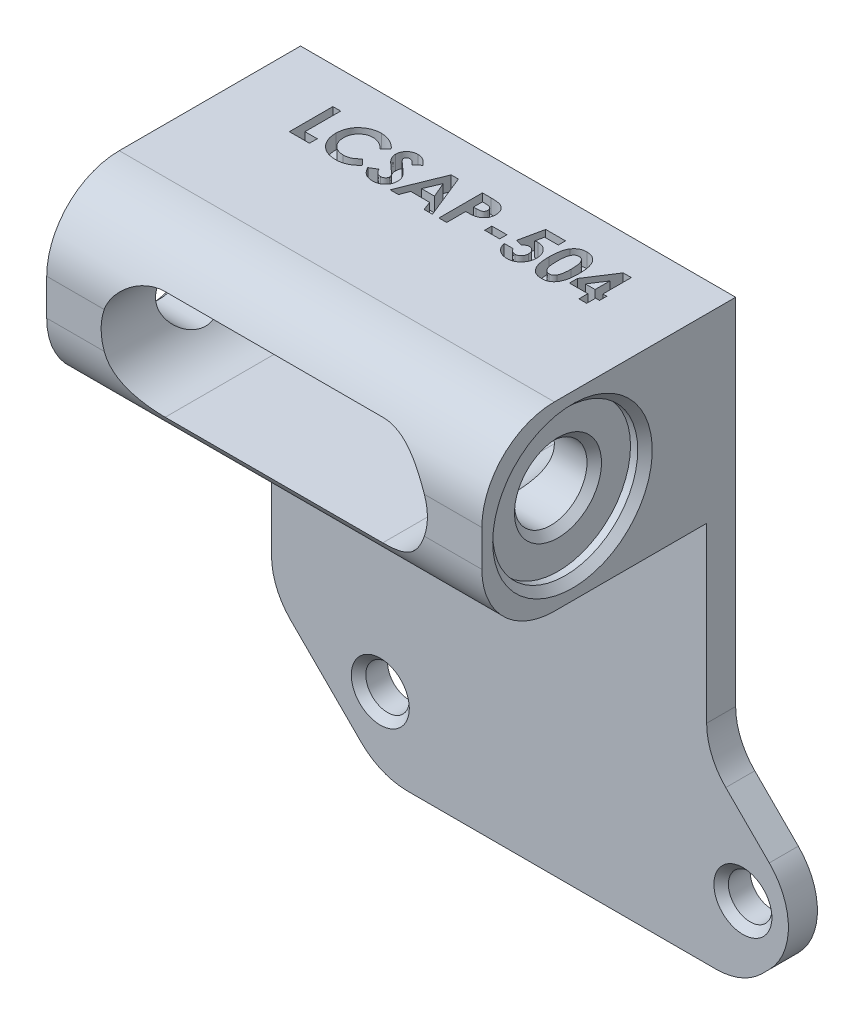
from build123d import *

# Parameters (mm, degrees)
SKETCH1_R           = 1.905
BOSS_EXTRUDE1_DEPTH = 2.54
SKETCH1_3_W         = 50.8
SKETCH1_3_H         = 15.875
BOSS_EXTRUDE2_DEPTH = 22.225
CUT_EXTRUDE6_DEPTH  = 75.180285798
FILLET2_R           = 5.715
SKETCH2_R           = 3.175
CUT_EXTRUDE1_DEPTH  = 67.133840059
SKETCH3_R           = 6.35
CUT_EXTRUDE2_DEPTH  = 1.27
CUT_EXTRUDE3_START  = -1.27
SKETCH4_R           = 6.35
CUT_EXTRUDE3_DEPTH  = 1.27
FILLET1_R           = 6.35
CHAMFER1_SIZE       = 0.635
CUT_EXTRUDE4_DEPTH  = 71.500641843
SKETCH6_W           = 1.318846153
SKETCH6_H           = 0.635
CUT_EXTRUDE5_DEPTH  = 1.27


with BuildPart() as part:
    # Sketch1 → Boss-Extrude1 (new body)
    with BuildSketch(Plane.XY):
        Polygon((50.8, 0), (0, 0), (0, -39.751), (9.525, -49.276), (41.275, -49.276), (50.8, -39.751), align=None)
        with Locations((41.275, -42.926)):
            Circle(SKETCH1_R, mode=Mode.SUBTRACT)
        with Locations((9.525, -42.926)):
            Circle(SKETCH1_R, mode=Mode.SUBTRACT)
    extrude(amount=BOSS_EXTRUDE1_DEPTH)

    # Sketch1_3 → Boss-Extrude2 (add)
    with BuildSketch(Plane.XY):
        with Locations((25.4, -7.9375)):
            Rectangle(SKETCH1_3_W, SKETCH1_3_H)
    extrude(amount=BOSS_EXTRUDE2_DEPTH)

    # Sketch7 → Cut-Extrude6 (cut, through all)
    with BuildSketch(Plane.XY.offset(22.225)):
        Polygon((50.8, 0), (38.1, 0), (38.1, -33.401), (50.8, -46.101), (50.8, -33.401), align=None)
    extrude(amount=-CUT_EXTRUDE6_DEPTH, mode=Mode.SUBTRACT)

    # Fillet2
    fillet2_edges = [part.edges().sort_by_distance(p)[0] for p in [
        (0, -39.751, 1.27),
        (9.525, -49.276, 1.27),
        (41.275, -49.276, 1.27),
        (38.1, -33.401, 1.27),
        (47.625, -42.926, 1.27),
    ]]
    fillet(fillet2_edges, radius=FILLET2_R)

    # Sketch2 → Cut-Extrude1 (cut, through all)
    with BuildSketch(Plane(origin=(38.1, 0, 0), x_dir=(0, 0, -1), z_dir=(1, 0, 0))):
        with Locations((-14.2875, -7.9375)):
            Circle(SKETCH2_R)
    extrude(amount=-CUT_EXTRUDE1_DEPTH, mode=Mode.SUBTRACT)

    # Sketch3 → Cut-Extrude2 (cut)
    with BuildSketch(Plane(origin=(38.1, 0, 0), x_dir=(0, 0, -1), z_dir=(1, 0, 0))):
        with Locations((-14.2875, -7.9375)):
            Circle(SKETCH3_R)
    extrude(amount=-CUT_EXTRUDE2_DEPTH, mode=Mode.SUBTRACT)

    # Sketch4 → Cut-Extrude3 (cut)
    with BuildSketch(Plane.ZY.offset(CUT_EXTRUDE3_START)):
        with Locations((14.2875, -7.9375)):
            Circle(SKETCH4_R)
    extrude(amount=CUT_EXTRUDE3_DEPTH, mode=Mode.SUBTRACT)

    # Fillet1
    fillet1_edges = [part.edges().sort_by_distance(p)[0] for p in [
        (19.05, -15.875, 22.225),
        (19.05, 0, 22.225),
    ]]
    fillet(fillet1_edges, radius=FILLET1_R)

    # Chamfer1
    chamfer1_edges = [part.edges().sort_by_distance(p)[0] for p in [
        (1.27, -7.9375, 17.4625),
        (36.83, -7.9375, 17.4625),
        (0, -7.9375, 7.9375),
        (39.37, -42.926, 2.54),
        (7.62, -42.926, 2.54),
        (38.1, -7.9375, 20.6375),
    ]]
    chamfer(chamfer1_edges, length=CHAMFER1_SIZE)

    # Sketch5 → Cut-Extrude4 (cut, through all)
    with BuildSketch(Plane.XY.offset(22.225)):
        with BuildLine():
            Line((9.525, -3.175), (28.575, -3.175))
            ThreePointArc((28.575, -3.175), (33.3375, -7.9375), (28.575, -12.7))
            Line((28.575, -12.7), (9.525, -12.7))
            ThreePointArc((9.525, -12.7), (4.7625, -7.9375), (9.525, -3.175))
        make_face()
    extrude(amount=-CUT_EXTRUDE4_DEPTH, mode=Mode.SUBTRACT)

    # Sketch6 → Cut-Extrude5 (cut)
    # profile 1 of 9: a face of its own
    with BuildSketch(Plane(origin=(0, 0, 0), x_dir=(1, 0, 0), z_dir=(0, 1, 0))):
        Polygon((31.330228365, -3.077307692), (32.043076923, -3.077307692), (32.043076923, -5.568461538), (32.385, -5.568461538), (32.385, -6.203461538), (32.043076923, -6.203461538), (32.043076923, -6.985), (31.359230769, -6.985), (31.359230769, -6.203461538), (29.747307692, -6.203461538), (29.747307692, -5.511219952), align=None)
        Polygon((31.359230769, -5.568461538), (31.359230769, -4.271748798), (30.515871394, -5.568461538), align=None, mode=Mode.SUBTRACT)
    # profile 2 of 9: a face of its own
    with BuildSketch(Plane(origin=(0, 0, 0), x_dir=(1, 0, 0), z_dir=(0, 1, 0))):
        with BuildLine():
            add(Edge.make_bspline(
                [(28.148359375, -3.077307692), (28.181460367, -3.077799086), (28.246545762, -3.078765297), (28.342404296, -3.089230149), (28.434742569, -3.105039623), (28.523921817, -3.127088325), (28.60930012, -3.156268998), (28.69149888, -3.191197763), (28.769539692, -3.233706706), (28.844417826, -3.28172274), (28.91610444, -3.336083697), (28.982876595, -3.398057995), (29.045953694, -3.466219603), (29.103970349, -3.541599002), (29.158211357, -3.623510536), (29.208498491, -3.711967195), (29.25444679, -3.807401913), (29.296571226, -3.909986911), (29.334239029, -4.021259893), (29.365966573, -4.142497209), (29.393178251, -4.273726545), (29.416146827, -4.415274551), (29.433507358, -4.567329379), (29.445208706, -4.72979001), (29.453238724, -4.902343244), (29.453894079, -5.020713345), (29.454230769, -5.081526442)],
                knots=[0, 0, 0, 0, 0.879237366, 1.728815576, 2.559023295, 3.367336655, 4.166867292, 4.954216142, 5.737608147, 6.525189134, 7.316157332, 8.124696809, 8.942788509, 9.781158001, 10.649253743, 11.551476218, 12.482711956, 13.461909668, 14.496590415, 15.601789533, 16.789733467, 18.056700938, 19.410929216, 20.8549011, 22.384193279, 24, 24, 24, 24], degree=3))
            add(Edge.make_bspline(
                [(29.454230769, -5.081526442), (29.453866898, -5.14310038), (29.453159901, -5.262737435), (29.445542516, -5.436868929), (29.432425019, -5.600509122), (29.415518241, -5.753641084), (29.392360581, -5.896183948), (29.365239741, -6.028506806), (29.333011388, -6.150561692), (29.294102819, -6.262073591), (29.252233364, -6.364838751), (29.206159376, -6.460087394), (29.156683919, -6.548077507), (29.104941811, -6.63013654), (29.04809636, -6.703845435), (28.988914392, -6.77171068), (28.924819021, -6.8311472), (28.858508908, -6.885218086), (28.787554846, -6.931946184), (28.712688567, -6.972813807), (28.632575333, -7.005962303), (28.548675473, -7.034793095), (28.459558897, -7.055490492), (28.366641656, -7.071913197), (28.268874731, -7.080989391), (28.202311071, -7.082115353), (28.168203125, -7.082692308)],
                knots=[0, 0, 0, 0, 1.643780988, 3.193836972, 4.651895693, 6.025988579, 7.305620092, 8.505800249, 9.631074763, 10.672816429, 11.65661981, 12.592235626, 13.49536222, 14.350718032, 15.179365177, 15.97804903, 16.751647189, 17.51006938, 18.259804725, 19.016521909, 19.783502495, 20.571750527, 21.382245291, 22.22305063, 23.089471752, 24, 24, 24, 24], degree=3))
            add(Edge.make_bspline(
                [(28.168203125, -7.082692308), (28.1340961, -7.082104224), (28.067280939, -7.080952176), (27.969249643, -7.071980682), (27.875839986, -7.055423964), (27.786018355, -7.034634195), (27.700409894, -7.006026094), (27.618604112, -6.971885819), (27.541230026, -6.931273189), (27.468073398, -6.88443622), (27.399384007, -6.830727108), (27.334094419, -6.770720333), (27.27234906, -6.704567997), (27.215087228, -6.631529138), (27.161371141, -6.552578674), (27.111760973, -6.466815027), (27.066286538, -6.374363069), (27.023525387, -6.27509393), (26.98637136, -6.166870459), (26.953306, -6.048726236), (26.926219728, -5.919676429), (26.904435135, -5.779762499), (26.887042329, -5.629280858), (26.87410408, -5.468158874), (26.866444384, -5.2963215), (26.865744802, -5.178209113), (26.865384615, -5.117397837)],
                knots=[0, 0, 0, 0, 0.917216111, 1.796812873, 2.643793957, 3.46689424, 4.273913431, 5.068098542, 5.848489301, 6.620921603, 7.401012384, 8.190319798, 9.003608147, 9.831726257, 10.68377682, 11.569763213, 12.493818149, 13.453288342, 14.474581811, 15.568529029, 16.750744269, 18.018426408, 19.375425659, 20.823733699, 22.36466933, 24, 24, 24, 24], degree=3))
            add(Edge.make_bspline(
                [(26.865384615, -5.117397837), (26.866037059, -5.032905355), (26.867295958, -4.869876023), (26.883249648, -4.63434604), (26.906665618, -4.416639369), (26.941058131, -4.217120182), (26.983583997, -4.035049518), (27.038040584, -3.871626761), (27.100035447, -3.724590593), (27.152863035, -3.637485482), (27.178305288, -3.595534856)],
                knots=[0, 0, 0, 0, 1.288568992, 2.486310467, 3.599230591, 4.627010532, 5.572937695, 6.447898582, 7.252493626, 8, 8, 8, 8], degree=3))
            add(Edge.make_bspline(
                [(27.178305288, -3.595534856), (27.207888329, -3.554322574), (27.265729004, -3.473744442), (27.36686504, -3.367960418), (27.475522543, -3.27748874), (27.593933276, -3.204376863), (27.720224525, -3.146720832), (27.855480563, -3.105999026), (27.999201912, -3.082272605), (28.097897761, -3.078987377), (28.148359375, -3.077307692)],
                knots=[0, 0, 0, 0, 1.058512271, 2.069600068, 3.047294572, 4.004278952, 4.967380941, 5.939006123, 6.946246673, 8, 8, 8, 8], degree=3))
        make_face()
        with BuildLine():
            add(Edge.make_bspline(
                [(28.16515024, -3.761153846), (28.135226669, -3.762572164), (28.076560585, -3.76535282), (27.991433301, -3.788956664), (27.911163588, -3.825414074), (27.850104561, -3.869284867), (27.804402486, -3.911340283), (27.772470119, -3.949399067), (27.741676384, -3.991869927), (27.714477806, -4.040669355), (27.688795249, -4.094043929), (27.66369565, -4.152235938), (27.643120569, -4.216674703), (27.622906097, -4.286262825), (27.605196334, -4.36292423), (27.590359435, -4.44728554), (27.57710397, -4.539895365), (27.567858125, -4.640814364), (27.559238222, -4.74993695), (27.553059068, -4.867506208), (27.550475719, -4.993490419), (27.549654551, -5.080253876), (27.549230769, -5.125030048)],
                knots=[0, 0, 0, 0, 1.076674018, 2.110852608, 3.161083442, 4.239746716, 4.804137807, 5.395870207, 6.026861976, 6.692161227, 7.405688833, 8.16177676, 8.973626916, 9.841385931, 10.773283133, 11.807421078, 12.927755683, 14.143907515, 15.458935494, 16.872852025, 18.386167141, 20, 20, 20, 20], degree=3))
            add(Edge.make_bspline(
                [(27.549230769, -5.125030048), (27.549928262, -5.183039744), (27.551265758, -5.294277637), (27.558270931, -5.454241601), (27.572312221, -5.599821688), (27.589776751, -5.73200455), (27.614306395, -5.849932944), (27.64252934, -5.954722584), (27.677382166, -6.045037654), (27.717661323, -6.122184315), (27.762272304, -6.18781282), (27.810699486, -6.243597344), (27.861294097, -6.29190411), (27.91563536, -6.331143101), (27.973593633, -6.361214055), (28.03468507, -6.382843721), (28.098948495, -6.39608414), (28.142955426, -6.39792016), (28.16515024, -6.398846154)],
                knots=[0, 0, 0, 0, 1.771748488, 3.397459088, 4.888034009, 6.237357457, 7.467047327, 8.564189669, 9.548206622, 10.417051504, 11.216568818, 11.965764335, 12.669334354, 13.348544111, 14.005342236, 14.656555988, 15.322436492, 16, 16, 16, 16], degree=3))
            add(Edge.make_bspline(
                [(28.16515024, -6.398846154), (28.186583399, -6.39821252), (28.228546859, -6.396971945), (28.289738981, -6.384237601), (28.3476066, -6.363534325), (28.401974995, -6.334248086), (28.453038634, -6.297006154), (28.50054795, -6.25164487), (28.544144638, -6.197712088), (28.569544266, -6.157685987), (28.582632212, -6.137061298)],
                knots=[0, 0, 0, 0, 0.992283464, 1.942767638, 2.88273346, 3.832339453, 4.79467288, 5.803907806, 6.868395428, 8, 8, 8, 8], degree=3))
            add(Edge.make_bspline(
                [(28.582632212, -6.137061298), (28.598041063, -6.10887832), (28.630352176, -6.0497809), (28.667742651, -5.950056207), (28.699215869, -5.837583236), (28.726304407, -5.712011961), (28.744831315, -5.572847111), (28.760786666, -5.420971144), (28.768482328, -5.255619274), (28.769734069, -5.141062902), (28.770384615, -5.081526442)],
                knots=[0, 0, 0, 0, 0.710965849, 1.490837728, 2.352621235, 3.297892224, 4.334225155, 5.461620853, 6.680770821, 8, 8, 8, 8], degree=3))
            add(Edge.make_bspline(
                [(28.770384615, -5.081526442), (28.770133323, -5.021473177), (28.769649629, -4.905880893), (28.760775239, -4.739934572), (28.748416972, -4.588370148), (28.730340396, -4.451526005), (28.707081596, -4.329069943), (28.678415036, -4.221009969), (28.644619294, -4.127133116), (28.604541572, -4.047532993), (28.560153005, -3.979883808), (28.513033186, -3.921846055), (28.462982874, -3.872294885), (28.410085768, -3.83104383), (28.353117547, -3.79952493), (28.293166377, -3.777269979), (28.230109356, -3.763806479), (28.18709554, -3.762049992), (28.16515024, -3.761153846)],
                knots=[0, 0, 0, 0, 1.793836731, 3.452829483, 4.963243077, 6.335886805, 7.574563692, 8.684454726, 9.672768357, 10.54971625, 11.340229787, 12.085688095, 12.778991901, 13.440269426, 14.083255152, 14.715733572, 15.344777694, 16, 16, 16, 16], degree=3))
        make_face(mode=Mode.SUBTRACT)
    # profile 3 of 9: a face of its own
    with BuildSketch(Plane(origin=(0, 0, 0), x_dir=(1, 0, 0), z_dir=(0, 1, 0))):
        with BuildLine():
            Line((24.642121394, -3.175), (26.376923077, -3.175))
            Line((26.376923077, -3.175), (26.376923077, -3.81))
            Line((26.376923077, -3.81), (25.184008413, -3.81))
            Line((25.184008413, -3.81), (25.035180288, -4.530480769))
            add(Edge.make_bspline(
                [(25.035180288, -4.530480769), (25.055460251, -4.524832544), (25.095456504, -4.513693082), (25.155710908, -4.502521612), (25.214105823, -4.49528062), (25.252424209, -4.494314768), (25.271015625, -4.493846154)],
                knots=[0, 0, 0, 0, 1.05461699, 2.079921384, 3.068411212, 4, 4, 4, 4], degree=3))
            add(Edge.make_bspline(
                [(25.271015625, -4.493846154), (25.311528267, -4.494774478), (25.391387609, -4.496604408), (25.508211693, -4.513976418), (25.620077654, -4.541336807), (25.726643171, -4.580358366), (25.827804143, -4.631145934), (25.923683198, -4.692584654), (26.01439801, -4.764782435), (26.098337103, -4.847784479), (26.175463849, -4.938922602), (26.242521155, -5.037498127), (26.299792279, -5.14210546), (26.345343751, -5.25339484), (26.381296856, -5.370667295), (26.407277372, -5.493997975), (26.42264095, -5.623533047), (26.424712634, -5.711905564), (26.425769231, -5.756977163)],
                knots=[0, 0, 0, 0, 1.01440847, 1.999622559, 2.951875003, 3.895578053, 4.836219714, 5.782137149, 6.743708247, 7.735272588, 8.734977101, 9.730283169, 10.717124674, 11.717316708, 12.737475749, 13.78628267, 14.87096371, 16, 16, 16, 16], degree=3))
            add(Edge.make_bspline(
                [(26.425769231, -5.756977163), (26.424478052, -5.802560429), (26.42193018, -5.892509538), (26.405307649, -6.024766545), (26.375968583, -6.151438899), (26.33566844, -6.272865702), (26.282575581, -6.388154493), (26.218724152, -6.498499579), (26.143034598, -6.603081904), (26.056249691, -6.700829373), (25.961903114, -6.790172435), (25.86144628, -6.868767698), (25.755584929, -6.934904975), (25.644316508, -6.988355077), (25.528279398, -7.030643845), (25.40743838, -7.06142805), (25.281206183, -7.079081081), (25.195510923, -7.081475338), (25.151953125, -7.082692308)],
                knots=[0, 0, 0, 0, 1.06808661, 2.107647099, 3.116961351, 4.110378221, 5.100014249, 6.085620622, 7.093190682, 8.119403071, 9.144090782, 10.133780668, 11.103064255, 12.062861538, 13.020824475, 13.992378307, 14.979551724, 16, 16, 16, 16], degree=3))
            add(Edge.make_bspline(
                [(25.151953125, -7.082692308), (25.113000683, -7.081696751), (25.036178315, -7.079733304), (24.923022339, -7.067664925), (24.813927413, -7.046327917), (24.709472711, -7.015447743), (24.608559196, -6.977441298), (24.512353455, -6.929907056), (24.420326823, -6.873750133), (24.33274062, -6.809995395), (24.251017997, -6.738178154), (24.176430246, -6.659561811), (24.108525804, -6.575137285), (24.048757719, -6.483863035), (23.997313346, -6.385873913), (23.951691427, -6.282324743), (23.914349429, -6.172134142), (23.89539944, -6.095743896), (23.885769231, -6.056923077)],
                knots=[0, 0, 0, 0, 1.054957082, 2.080596141, 3.077793124, 4.061112343, 5.027190972, 5.994718051, 6.962465889, 7.943658696, 8.924948258, 9.904494768, 10.875059, 11.855380583, 12.854004648, 13.869083016, 14.917087635, 16, 16, 16, 16], degree=3))
            Line((23.885769231, -6.056923077), (24.667307692, -6.056923077))
            add(Edge.make_bspline(
                [(24.667307692, -6.056923077), (24.681594234, -6.083824324), (24.709358498, -6.136103827), (24.762172266, -6.205512722), (24.821293926, -6.264701647), (24.886190169, -6.314248888), (24.957281483, -6.351368838), (25.031671029, -6.379518891), (25.110293333, -6.395785764), (25.163838594, -6.397819285), (25.190877404, -6.398846154)],
                knots=[0, 0, 0, 0, 1.104910296, 2.147267069, 3.153527244, 4.136738762, 5.099945312, 6.05603338, 7.018353, 8, 8, 8, 8], degree=3))
            add(Edge.make_bspline(
                [(25.190877404, -6.398846154), (25.209723092, -6.398137092), (25.2468023, -6.396742), (25.301432651, -6.389361616), (25.35357972, -6.375383335), (25.40363121, -6.356026666), (25.451721571, -6.331886714), (25.497161411, -6.301411596), (25.540741302, -6.266333606), (25.58179778, -6.226081494), (25.618983116, -6.181209752), (25.651590588, -6.132992006), (25.680746164, -6.082499665), (25.702342145, -6.027732601), (25.720027428, -5.970326177), (25.733051585, -5.909847359), (25.740834988, -5.846225514), (25.741555523, -5.802792663), (25.741923077, -5.780637019)],
                knots=[0, 0, 0, 0, 0.978869489, 1.925942215, 2.855067702, 3.774946051, 4.70828698, 5.642468714, 6.60995405, 7.609372294, 8.622401667, 9.629904756, 10.629323, 11.642352373, 12.678539694, 13.745912462, 14.850161547, 16, 16, 16, 16], degree=3))
            add(Edge.make_bspline(
                [(25.741923077, -5.780637019), (25.741496488, -5.758995658), (25.740666123, -5.716870222), (25.733797173, -5.655014994), (25.721508754, -5.596325577), (25.704765678, -5.540352453), (25.683332542, -5.487435519), (25.657139817, -5.437259788), (25.626075605, -5.39007888), (25.589973129, -5.34685335), (25.55147382, -5.307205666), (25.510113191, -5.272530117), (25.46626388, -5.243751819), (25.421288449, -5.218627528), (25.373391643, -5.200342616), (25.323650466, -5.187750472), (25.272117229, -5.178510863), (25.236967527, -5.177968002), (25.219116587, -5.177692308)],
                knots=[0, 0, 0, 0, 1.166249705, 2.270133367, 3.348514167, 4.393962215, 5.415026464, 6.420877785, 7.440098956, 8.453121383, 9.451844239, 10.415694839, 11.355045125, 12.27538808, 13.187007209, 14.108269027, 15.039275622, 16, 16, 16, 16], degree=3))
            add(Edge.make_bspline(
                [(25.219116587, -5.177692308), (25.199726317, -5.178428061), (25.160864057, -5.179902668), (25.103124464, -5.19190115), (25.046081051, -5.211319195), (24.989416597, -5.238109466), (24.933693595, -5.273169478), (24.877441487, -5.314290851), (24.822543152, -5.364461445), (24.787637264, -5.401828618), (24.769579327, -5.421159856)],
                knots=[0, 0, 0, 0, 0.88288272, 1.769486374, 2.674910571, 3.623812639, 4.617874466, 5.670434592, 6.794841017, 8, 8, 8, 8], degree=3))
            Line((24.769579327, -5.421159856), (24.194110577, -5.289122596))
            Line((24.194110577, -5.289122596), (24.642121394, -3.175))
        make_face()
    # profile 4 of 9: a face of its own
    with BuildSketch(Plane(origin=(0, 0, 0), x_dir=(1, 0, 0), z_dir=(0, 1, 0))):
        with Locations((22.689038462, -5.592884615)):
            Rectangle(SKETCH6_W, SKETCH6_H)
    # profile 5 of 9: a face of its own
    with BuildSketch(Plane(origin=(0, 0, 0), x_dir=(1, 0, 0), z_dir=(0, 1, 0))):
        with BuildLine():
            Line((19.098846154, -3.175), (19.862067308, -3.175))
            add(Edge.make_bspline(
                [(19.862067308, -3.175), (19.911935188, -3.175223219), (20.008140781, -3.175653856), (20.146877163, -3.180875899), (20.274868267, -3.190234118), (20.392084689, -3.201799397), (20.498478233, -3.218013468), (20.594182134, -3.236601631), (20.679216253, -3.259247423), (20.754539478, -3.286127665), (20.822139638, -3.31781842), (20.886111194, -3.351571335), (20.945008379, -3.39185425), (21.001803913, -3.434325642), (21.053250698, -3.483042787), (21.102558292, -3.534763489), (21.147638383, -3.591538947), (21.188699857, -3.65268191), (21.22594894, -3.717062719), (21.258492232, -3.784796465), (21.284889527, -3.855990332), (21.307033575, -3.930183776), (21.324819891, -4.007373562), (21.336659029, -4.088034416), (21.344700767, -4.171603132), (21.345410339, -4.228480053), (21.345769231, -4.257247596)],
                knots=[0, 0, 0, 0, 1.698747864, 3.27724071, 4.728299578, 6.070144658, 7.288476769, 8.393259625, 9.389771311, 10.283485332, 11.113357557, 11.931608583, 12.74405601, 13.541433047, 14.344816069, 15.154114104, 15.974336324, 16.810834471, 17.661136416, 18.50621059, 19.367396281, 20.244825668, 21.142564693, 22.063065223, 23.020325768, 24, 24, 24, 24], degree=3))
            add(Edge.make_bspline(
                [(21.345769231, -4.257247596), (21.345249959, -4.289072444), (21.344229528, -4.35161218), (21.334226006, -4.443287761), (21.317136832, -4.530692127), (21.294802174, -4.614562375), (21.263658083, -4.693518653), (21.228077421, -4.769444883), (21.184301921, -4.840212326), (21.134281415, -4.906706198), (21.079653314, -4.969467124), (21.019120752, -5.026683003), (20.953837505, -5.078743873), (20.884181474, -5.126195335), (20.809891149, -5.16894167), (20.731020135, -5.207383151), (20.647029855, -5.240290301), (20.588541551, -5.257500474), (20.558888221, -5.266225962)],
                knots=[0, 0, 0, 0, 1.102006807, 2.165578795, 3.188629044, 4.184801286, 5.166646146, 6.124351954, 7.085497154, 8.042432466, 9.003981491, 9.963833307, 10.922997304, 11.89326795, 12.880200226, 13.889073926, 14.929769137, 16, 16, 16, 16], degree=3))
            add(Edge.make_bspline(
                [(20.558888221, -5.266225962), (20.539356832, -5.271085403), (20.497045554, -5.281612517), (20.42703201, -5.292300181), (20.346348752, -5.30212683), (20.254734877, -5.310571646), (20.152137569, -5.316312152), (20.038656168, -5.320795233), (19.914239247, -5.324054895), (19.82772464, -5.324170563), (19.782692308, -5.324230769)],
                knots=[0, 0, 0, 0, 0.618981996, 1.340914327, 2.176866532, 3.120127938, 4.170906482, 5.338178032, 6.614476169, 8, 8, 8, 8], degree=3))
            Line((19.782692308, -5.324230769), (19.782692308, -6.985))
            Line((19.782692308, -6.985), (19.098846154, -6.985))
            Line((19.098846154, -6.985), (19.098846154, -3.175))
        make_face()
        with BuildLine():
            Line((19.782692308, -4.640384615), (20.024633413, -4.640384615))
            add(Edge.make_bspline(
                [(20.024633413, -4.640384615), (20.068658417, -4.640105463), (20.149665079, -4.639591818), (20.260291572, -4.632164211), (20.34919315, -4.620820755), (20.419427047, -4.604551616), (20.474883361, -4.579861043), (20.52271096, -4.5512987), (20.563733913, -4.5151824), (20.599253752, -4.473913349), (20.627650793, -4.426493141), (20.647342662, -4.373693921), (20.660134113, -4.316625059), (20.661315522, -4.276908908), (20.661923077, -4.256484375)],
                knots=[0, 0, 0, 0, 1.8619151, 3.425951444, 4.686033666, 5.651700536, 6.461346321, 7.243864085, 7.999046032, 8.762387399, 9.539336099, 10.322741239, 11.137448474, 12, 12, 12, 12], degree=3))
            add(Edge.make_bspline(
                [(20.661923077, -4.256484375), (20.661321772, -4.238639727), (20.660155095, -4.204016818), (20.651584372, -4.154047374), (20.637925104, -4.107465544), (20.61813335, -4.064757813), (20.592547298, -4.025996749), (20.561352724, -3.991197621), (20.524949914, -3.959615176), (20.496844817, -3.942898106), (20.482566106, -3.934405048)],
                knots=[0, 0, 0, 0, 1.102301479, 2.1387299, 3.123554645, 4.094223062, 5.036071848, 5.982632524, 6.975082478, 8, 8, 8, 8], degree=3))
            add(Edge.make_bspline(
                [(20.482566106, -3.934405048), (20.470471213, -3.928288314), (20.444863848, -3.915337935), (20.401252022, -3.900282173), (20.35092464, -3.887580978), (20.293541937, -3.87703911), (20.229332828, -3.868857525), (20.158308769, -3.862600659), (20.080365241, -3.86008453), (20.026160182, -3.859270331), (19.997920673, -3.858846154)],
                knots=[0, 0, 0, 0, 0.656809284, 1.390599849, 2.23162475, 3.173112763, 4.218524733, 5.370385145, 6.63003504, 8, 8, 8, 8], degree=3))
            Line((19.997920673, -3.858846154), (19.782692308, -3.858846154))
            Line((19.782692308, -3.858846154), (19.782692308, -4.640384615))
        make_face(mode=Mode.SUBTRACT)
    # profile 6 of 9: a face of its own
    with BuildSketch(Plane(origin=(0, 0, 0), x_dir=(1, 0, 0), z_dir=(0, 1, 0))):
        Polygon((16.36422476, -3.175), (16.998461538, -3.175), (18.537115385, -6.985), (17.80671274, -6.985), (17.510582933, -6.203461538), (15.850576923, -6.203461538), (15.554447115, -6.985), (14.824807692, -6.985), align=None)
        Polygon((16.680961538, -4.196953125), (16.110072115, -5.519615385), (17.251850962, -5.519615385), align=None, mode=Mode.SUBTRACT)
    # profile 7 of 9: a face of its own
    with BuildSketch(Plane(origin=(0, 0, 0), x_dir=(1, 0, 0), z_dir=(0, 1, 0))):
        with BuildLine():
            Line((14.409615385, -3.68406851), (13.898257212, -4.151923077))
            add(Edge.make_bspline(
                [(13.898257212, -4.151923077), (13.87635282, -4.121024656), (13.834299443, -4.061703995), (13.766135305, -3.982272233), (13.698278964, -3.914511029), (13.63010177, -3.858703458), (13.560999428, -3.815188591), (13.491091889, -3.784379585), (13.420775479, -3.764794008), (13.373533706, -3.762355132), (13.350264423, -3.761153846)],
                knots=[0, 0, 0, 0, 1.299362458, 2.494594718, 3.587462134, 4.587049575, 5.512617175, 6.380583204, 7.202344345, 8, 8, 8, 8], degree=3))
            add(Edge.make_bspline(
                [(13.350264423, -3.761153846), (13.328559503, -3.761915036), (13.286653006, -3.763384694), (13.226912185, -3.777992984), (13.173873434, -3.803204747), (13.127588515, -3.836171248), (13.09092403, -3.87588824), (13.061650283, -3.917541151), (13.045166703, -3.963516546), (13.04299714, -3.995094301), (13.041923077, -4.010727163)],
                knots=[0, 0, 0, 0, 1.185010067, 2.2879431, 3.333075148, 4.379039566, 5.372662701, 6.27520591, 7.14612461, 8, 8, 8, 8], degree=3))
            add(Edge.make_bspline(
                [(13.041923077, -4.010727163), (13.042596138, -4.026585458), (13.043951588, -4.058521861), (13.057043394, -4.105328636), (13.076776485, -4.151064304), (13.095632259, -4.178905781), (13.105270433, -4.193137019)],
                knots=[0, 0, 0, 0, 0.967525499, 1.948461899, 2.951351359, 4, 4, 4, 4], degree=3))
            add(Edge.make_bspline(
                [(13.105270433, -4.193137019), (13.114032576, -4.204198812), (13.134201871, -4.229661597), (13.172660587, -4.26999068), (13.220956658, -4.319397337), (13.280948617, -4.376182618), (13.350146033, -4.442388743), (13.431756297, -4.515413124), (13.523430309, -4.597517242), (13.588590072, -4.654691576), (13.622734375, -4.684651442)],
                knots=[0, 0, 0, 0, 0.473873513, 1.090794244, 1.870441696, 2.795289791, 3.865433203, 5.087734844, 6.473946851, 8, 8, 8, 8], degree=3))
            add(Edge.make_bspline(
                [(13.622734375, -4.684651442), (13.654783715, -4.712388529), (13.715606702, -4.765027757), (13.802145736, -4.83974069), (13.878199133, -4.906958093), (13.944874819, -4.965671179), (14.001162055, -5.016495981), (14.047297473, -5.059675441), (14.083844539, -5.094368935), (14.104619406, -5.115323826), (14.113485577, -5.124266827)],
                knots=[0, 0, 0, 0, 1.543621617, 2.929473131, 4.163658386, 5.240097082, 6.164993805, 6.925417477, 7.541396219, 8, 8, 8, 8], degree=3))
            add(Edge.make_bspline(
                [(14.113485577, -5.124266827), (14.147121982, -5.160668621), (14.211782964, -5.230645652), (14.295819447, -5.339088044), (14.364984191, -5.44494993), (14.418491348, -5.550223274), (14.458902106, -5.65642696), (14.487392225, -5.766165628), (14.504455147, -5.880585978), (14.50634953, -5.958663899), (14.507307692, -5.998155048)],
                knots=[0, 0, 0, 0, 1.206664779, 2.319633467, 3.337109185, 4.282041471, 5.190008762, 6.099243693, 7.03861361, 8, 8, 8, 8], degree=3))
            add(Edge.make_bspline(
                [(14.507307692, -5.998155048), (14.506625697, -6.03663433), (14.505287596, -6.112132112), (14.488898426, -6.222611871), (14.465528432, -6.328345796), (14.429394322, -6.428183351), (14.385354282, -6.52376334), (14.330143731, -6.61359693), (14.26530651, -6.698593274), (14.190993099, -6.777232958), (14.108793642, -6.848593021), (14.020626913, -6.912119435), (13.925630772, -6.964568581), (13.824616852, -7.007756712), (13.717639223, -7.041020788), (13.604825328, -7.06560604), (13.48600261, -7.080361721), (13.404749923, -7.081904252), (13.363239183, -7.082692308)],
                knots=[0, 0, 0, 0, 1.043214005, 2.046824704, 3.02475056, 3.976699089, 4.921714032, 5.875962561, 6.831408892, 7.817874052, 8.806269674, 9.781291748, 10.760897367, 11.74438705, 12.757449933, 13.795994037, 14.874007457, 16, 16, 16, 16], degree=3))
            add(Edge.make_bspline(
                [(13.363239183, -7.082692308), (13.330653605, -7.082114218), (13.266115473, -7.080969268), (13.170996024, -7.071621709), (13.079147443, -7.056535743), (12.99067319, -7.034913047), (12.905174672, -7.007514158), (12.822648378, -6.974047466), (12.743664015, -6.933994248), (12.667623949, -6.888178158), (12.594897829, -6.834979642), (12.524566062, -6.775486327), (12.457327249, -6.708783179), (12.392858457, -6.635027948), (12.331572174, -6.554011777), (12.271462281, -6.466862966), (12.215200242, -6.371964152), (12.180444678, -6.305391867), (12.162692308, -6.271388221)],
                knots=[0, 0, 0, 0, 1.016823716, 2.013894106, 2.979844003, 3.91962641, 4.853723003, 5.779685073, 6.695824784, 7.614987388, 8.547259901, 9.504950863, 10.487499108, 11.500346958, 12.559593716, 13.656357062, 14.802919212, 16, 16, 16, 16], degree=3))
            Line((12.162692308, -6.271388221), (12.764110577, -5.910384615))
            add(Edge.make_bspline(
                [(12.764110577, -5.910384615), (12.786316139, -5.948983196), (12.8288861, -6.022979974), (12.901024879, -6.122404024), (12.974927375, -6.207544265), (13.052302148, -6.276895838), (13.132208349, -6.331386063), (13.215031944, -6.370328557), (13.300831124, -6.394433918), (13.359273627, -6.397377739), (13.388425481, -6.398846154)],
                knots=[0, 0, 0, 0, 1.283663364, 2.460892379, 3.537111102, 4.529833553, 5.449777664, 6.316464042, 7.160231139, 8, 8, 8, 8], degree=3))
            add(Edge.make_bspline(
                [(13.388425481, -6.398846154), (13.41807709, -6.397646967), (13.47560553, -6.395320369), (13.557720016, -6.373830284), (13.633005687, -6.340089276), (13.698082065, -6.291945509), (13.753184638, -6.236380285), (13.7938535, -6.174561433), (13.819401954, -6.107674927), (13.822103044, -6.06121116), (13.823461538, -6.037842548)],
                knots=[0, 0, 0, 0, 1.13588714, 2.203786484, 3.234766741, 4.283437687, 5.291419208, 6.222934724, 7.106237994, 8, 8, 8, 8], degree=3))
            add(Edge.make_bspline(
                [(13.823461538, -6.037842548), (13.822207025, -6.016101857), (13.819658601, -5.971937725), (13.800887693, -5.906272762), (13.771543039, -5.840637662), (13.736826244, -5.786801977), (13.701497559, -5.741726818), (13.667715367, -5.702671231), (13.626577593, -5.659521645), (13.578188545, -5.612223781), (13.523187569, -5.560361264), (13.461528333, -5.503939172), (13.392504774, -5.443454517), (13.343718786, -5.402252967), (13.318209135, -5.380709135)],
                knots=[0, 0, 0, 0, 0.916159276, 1.861089862, 2.860218735, 3.940849679, 4.552606315, 5.27541173, 6.11797699, 7.06649574, 8.129236253, 9.306560635, 10.591630461, 12, 12, 12, 12], degree=3))
            add(Edge.make_bspline(
                [(13.318209135, -5.380709135), (13.269714272, -5.339677831), (13.176637952, -5.260926339), (13.045109304, -5.144612865), (12.926590215, -5.035907265), (12.822104343, -4.933465702), (12.730320377, -4.839180033), (12.651859918, -4.752284434), (12.587584889, -4.672108624), (12.51994928, -4.577145743), (12.455681929, -4.461426947), (12.400136701, -4.322203821), (12.364101301, -4.18299836), (12.360064036, -4.08954348), (12.358076923, -4.043545673)],
                knots=[0, 0, 0, 0, 1.345494975, 2.582412109, 3.71882943, 4.751509156, 5.681369928, 6.505683931, 7.230279997, 7.856715994, 8.973648664, 10.023341002, 11.027102913, 12, 12, 12, 12], degree=3))
            add(Edge.make_bspline(
                [(12.358076923, -4.043545673), (12.358903361, -4.010926497), (12.360531531, -3.946663216), (12.375055063, -3.852173425), (12.396761035, -3.760998716), (12.428284338, -3.673471736), (12.469197779, -3.589702116), (12.518885563, -3.509279769), (12.578119249, -3.432944883), (12.644871614, -3.360748063), (12.718415629, -3.294768385), (12.797006756, -3.236534709), (12.880200161, -3.187349699), (12.96748691, -3.146547162), (13.059407881, -3.115315411), (13.155285898, -3.09317679), (13.25525848, -3.080009444), (13.323257672, -3.078219496), (13.357896635, -3.077307692)],
                knots=[0, 0, 0, 0, 1.010766082, 1.991317756, 2.957454644, 3.913069143, 4.869106762, 5.843196583, 6.838735724, 7.860187025, 8.887984031, 9.89767229, 10.887916223, 11.879572884, 12.879850636, 13.892031539, 14.926195476, 16, 16, 16, 16], degree=3))
            add(Edge.make_bspline(
                [(13.357896635, -3.077307692), (13.402787015, -3.078949878), (13.492213428, -3.082221287), (13.624432958, -3.107802634), (13.753579467, -3.148031997), (13.857648145, -3.196564297), (13.940453649, -3.243577559), (14.003916333, -3.286861449), (14.068493029, -3.336445471), (14.13470451, -3.392485877), (14.201320463, -3.456038544), (14.270235098, -3.525590548), (14.340509369, -3.601742983), (14.386176503, -3.656145929), (14.409615385, -3.68406851)],
                knots=[0, 0, 0, 0, 1.282922637, 2.555718331, 3.837320111, 5.142675274, 5.830281639, 6.55870424, 7.337177975, 8.157850921, 9.037902056, 9.96903443, 10.957596896, 12, 12, 12, 12], degree=3))
        make_face()
    # profile 8 of 9: a face of its own
    with BuildSketch(Plane(origin=(0, 0, 0), x_dir=(1, 0, 0), z_dir=(0, 1, 0))):
        with BuildLine():
            Line((11.771923077, -3.835949519), (11.270486779, -4.315252404))
            add(Edge.make_bspline(
                [(11.270486779, -4.315252404), (11.227950867, -4.2712702), (11.144864905, -4.185359176), (11.010982153, -4.071620551), (10.871748965, -3.976834797), (10.729873846, -3.897006838), (10.582804873, -3.836611298), (10.432242564, -3.79260005), (10.277225534, -3.765768056), (10.172315971, -3.762698001), (10.119549279, -3.761153846)],
                knots=[0, 0, 0, 0, 1.115251505, 2.178435587, 3.19620269, 4.182487026, 5.141301733, 6.088180966, 7.038406374, 8, 8, 8, 8], degree=3))
            add(Edge.make_bspline(
                [(10.119549279, -3.761153846), (10.075482678, -3.762373783), (9.988522097, -3.764781193), (9.860841176, -3.782429886), (9.738707776, -3.812442257), (9.621703815, -3.853804863), (9.510173583, -3.90732588), (9.403883243, -3.972963884), (9.303094849, -4.05012607), (9.209139757, -4.138413199), (9.12319294, -4.234873521), (9.047253456, -4.337796454), (8.983641956, -4.446946209), (8.931437033, -4.561217395), (8.890771416, -4.681138918), (8.861731056, -4.80663004), (8.844934888, -4.937840213), (8.842427947, -5.027035911), (8.841153846, -5.072367788)],
                knots=[0, 0, 0, 0, 1.035432265, 2.043311493, 3.022114605, 3.98653278, 4.95457646, 5.923598177, 6.917315552, 7.932509744, 8.948865224, 9.949768934, 10.933144597, 11.912367597, 12.897413939, 13.903909035, 14.934704909, 16, 16, 16, 16], degree=3))
            add(Edge.make_bspline(
                [(8.841153846, -5.072367788), (8.841521028, -5.104184872), (8.84224475, -5.166896997), (8.850167167, -5.259665635), (8.862924127, -5.349673146), (8.881386609, -5.436783192), (8.904474125, -5.521071263), (8.931561037, -5.603264508), (8.96554117, -5.682227202), (9.003259631, -5.758876445), (9.047125766, -5.831120766), (9.094421551, -5.900011723), (9.145706109, -5.965211617), (9.201311612, -6.026453911), (9.262020639, -6.082781523), (9.326264085, -6.135888294), (9.395125649, -6.184444779), (9.467174901, -6.229669558), (9.543034256, -6.268956708), (9.620645475, -6.304543276), (9.701185299, -6.33344486), (9.783673107, -6.356742174), (9.867814118, -6.37655306), (9.954431308, -6.388751231), (10.042773815, -6.397988763), (10.102478521, -6.398559127), (10.132524038, -6.398846154)],
                knots=[0, 0, 0, 0, 1.103660481, 2.175337485, 3.227646561, 4.255952547, 5.262355991, 6.258840057, 7.255597736, 8.242457506, 9.22035537, 10.185017736, 11.140346927, 12.096287581, 13.051739095, 14.01125915, 14.986044842, 15.97314143, 16.960198552, 17.947847494, 18.933482797, 19.925264591, 20.920966487, 21.929612487, 22.958107872, 24, 24, 24, 24], degree=3))
            add(Edge.make_bspline(
                [(10.132524038, -6.398846154), (10.183486399, -6.397372052), (10.283614186, -6.394475825), (10.43056611, -6.37182774), (10.570596653, -6.334572923), (10.682480387, -6.290577148), (10.770138338, -6.24713075), (10.83687104, -6.20694497), (10.905877855, -6.161992764), (10.976012638, -6.110577586), (11.048064268, -6.053316439), (11.120760866, -5.988955196), (11.195963479, -5.919613182), (11.245227965, -5.870122424), (11.270486779, -5.844747596)],
                knots=[0, 0, 0, 0, 1.404581149, 2.759636711, 4.088442092, 5.392261763, 6.066678138, 6.783632037, 7.538459478, 8.336747902, 9.180226004, 10.074962426, 11.012997595, 12, 12, 12, 12], degree=3))
            Line((11.270486779, -5.844747596), (11.756658654, -6.355342548))
            add(Edge.make_bspline(
                [(11.756658654, -6.355342548), (11.722483388, -6.388337694), (11.655780577, -6.452737164), (11.555161239, -6.544178401), (11.454668535, -6.626348518), (11.356730158, -6.702229929), (11.259741776, -6.769612026), (11.163713675, -6.828562102), (11.069732935, -6.880571091), (10.975848015, -6.924761887), (10.881474714, -6.962284463), (10.784375679, -6.994588938), (10.684254067, -7.021917361), (10.580498382, -7.043967809), (10.474076393, -7.061649292), (10.363992133, -7.073584191), (10.250943589, -7.081607626), (10.17426101, -7.082328599), (10.135576923, -7.082692308)],
                knots=[0, 0, 0, 0, 1.244526981, 2.429050516, 3.560637417, 4.644440555, 5.67424972, 6.652764056, 7.595344123, 8.486817594, 9.369275933, 10.254498637, 11.166417451, 12.086725134, 13.032340136, 13.991389299, 14.986715468, 16, 16, 16, 16], degree=3))
            add(Edge.make_bspline(
                [(10.135576923, -7.082692308), (10.064519047, -7.080880901), (9.925478536, -7.077336481), (9.721718292, -7.051074729), (9.528151529, -7.007047365), (9.344307337, -6.944780528), (9.170244173, -6.865237562), (9.006006568, -6.767721621), (8.851859237, -6.652491789), (8.709047386, -6.520898672), (8.57986727, -6.375565121), (8.465687007, -6.219516758), (8.37123709, -6.051986663), (8.292813288, -5.87544979), (8.231486906, -5.689100533), (8.18832353, -5.492737319), (8.161704991, -5.286549749), (8.158792885, -5.145718885), (8.157307692, -5.073894231)],
                knots=[0, 0, 0, 0, 1.078019885, 2.10938526, 3.111377082, 4.085535484, 5.04941344, 6.010039228, 6.978205633, 7.964457913, 8.951525778, 9.924444315, 10.892603023, 11.863865945, 12.85144698, 13.863884204, 14.910567087, 16, 16, 16, 16], degree=3))
            add(Edge.make_bspline(
                [(8.157307692, -5.073894231), (8.157935263, -5.027050804), (8.159178954, -4.934218582), (8.172250267, -4.797469197), (8.190472436, -4.664163007), (8.219380252, -4.535684173), (8.254225772, -4.410301847), (8.297560754, -4.289378789), (8.349315987, -4.172567454), (8.407823277, -4.059672293), (8.474011989, -3.95143289), (8.547952047, -3.848779192), (8.627739944, -3.750918731), (8.715292855, -3.659149808), (8.80933852, -3.572666674), (8.910301546, -3.491937998), (9.017574689, -3.415806039), (9.1314483, -3.346234057), (9.249710115, -3.2833025), (9.370868544, -3.22779418), (9.494625914, -3.181402007), (9.620458966, -3.14292141), (9.748899346, -3.114198366), (9.879030277, -3.092455948), (10.011959017, -3.080301798), (10.101209151, -3.078312086), (10.146262019, -3.077307692)],
                knots=[0, 0, 0, 0, 1.071919942, 2.124283339, 3.142214191, 4.149696895, 5.136002878, 6.119640489, 7.086990633, 8.058538607, 9.028339693, 9.988281803, 10.952401235, 11.916291999, 12.888973767, 13.874849856, 14.873389453, 15.898127285, 16.927174885, 17.938320013, 18.946391617, 19.950418109, 20.947802303, 21.956882652, 22.968648068, 24, 24, 24, 24], degree=3))
            add(Edge.make_bspline(
                [(10.146262019, -3.077307692), (10.184696736, -3.077883436), (10.261166554, -3.079028936), (10.375042946, -3.088577929), (10.488008609, -3.103574525), (10.599659089, -3.126201195), (10.710793026, -3.153061912), (10.819949995, -3.188232316), (10.928852006, -3.227436359), (11.035791093, -3.274296787), (11.140916528, -3.325449177), (11.241765581, -3.383483421), (11.340031499, -3.444828157), (11.433536767, -3.513114035), (11.524032942, -3.585864198), (11.61104681, -3.663418068), (11.693814774, -3.747068695), (11.745755353, -3.806172802), (11.771923077, -3.835949519)],
                knots=[0, 0, 0, 0, 0.996412454, 1.982464992, 2.961075852, 3.949442424, 4.934965278, 5.923860011, 6.921385422, 7.934793307, 8.949617135, 9.951082467, 10.950285876, 11.951772932, 12.951063433, 13.960125323, 14.972308753, 16, 16, 16, 16], degree=3))
        make_face()
    # profile 9 of 9: a face of its own
    with BuildSketch(Plane(origin=(0, 0, 0), x_dir=(1, 0, 0), z_dir=(0, 1, 0))):
        Polygon((6.008076923, -3.175), (6.691923077, -3.175), (6.691923077, -6.301153846), (7.766538462, -6.301153846), (7.766538462, -6.985), (6.008076923, -6.985), align=None)
    extrude(amount=-CUT_EXTRUDE5_DEPTH, mode=Mode.SUBTRACT)


solid = part.part
